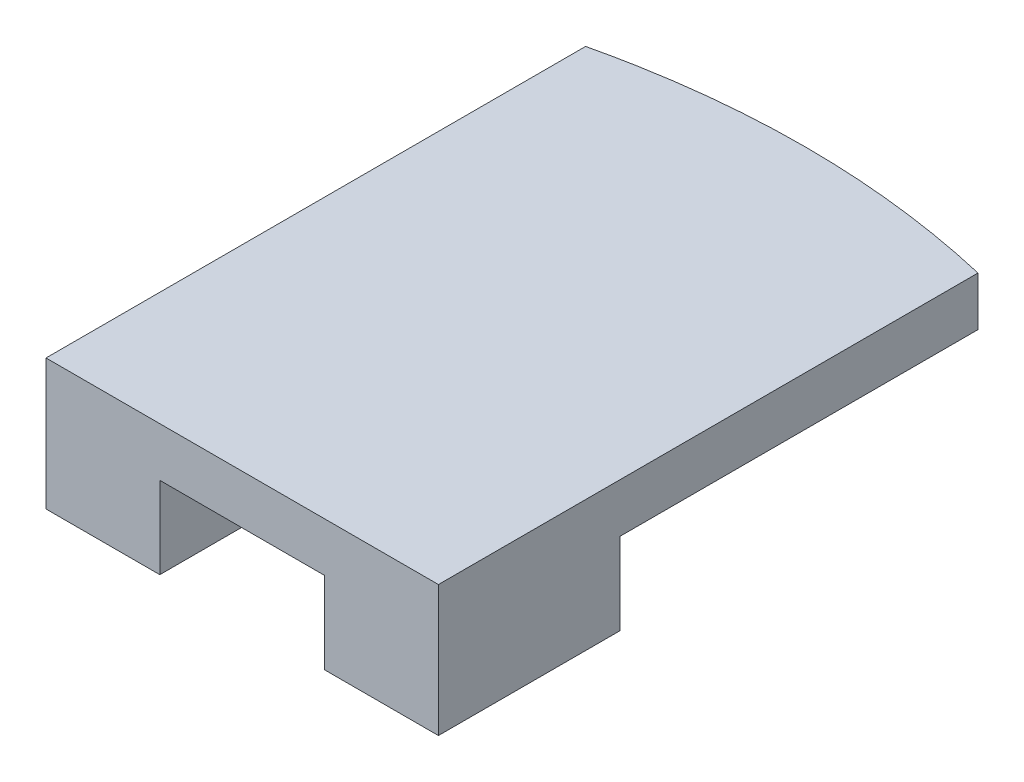
from build123d import *

# Parameters (mm, degrees)
BOSS_EXTRUDE1_DEPTH = 3
SKETCH4_W           = 24
SKETCH4_H           = 0.6
CUT_EXTRUDE3_DEPTH  = 4.0000001
SKETCH5_W           = 6.959988298
SKETCH5_H           = 11.094755151
BOSS_EXTRUDE2_DEPTH = 5


with BuildPart() as part:
    # Sketch1 → Boss-Extrude1 (new body)
    with BuildSketch(Plane(origin=(0, 0, 0), x_dir=(1, 0, 0), z_dir=(0, 1, 0))):
        with BuildLine():
            Line((0, 0), (24, 0))
            Line((24, 0), (24, 33.6))
            add(Edge.make_bspline(
                [(0, 33.6), (12, 36.4), (24, 33.6)],
                knots=[0, 0, 0, 1, 1, 1], degree=2))
            Line((0, 33.6), (0, 0))
        make_face()
    extrude(amount=BOSS_EXTRUDE1_DEPTH)

    # Sketch4 → Cut-Extrude3 (cut, through all)
    with BuildSketch(Plane(origin=(0, 3, 0), x_dir=(1, 0, 0), z_dir=(0, 1, 0))):
        with Locations((12, 0.3)):
            Rectangle(SKETCH4_W, SKETCH4_H)
    extrude(amount=-CUT_EXTRUDE3_DEPTH, mode=Mode.SUBTRACT)

    # Sketch5 → Boss-Extrude2 (add)
    with BuildSketch(Plane.XZ):
        with Locations((3.479994149, -6.147377576)):
            Rectangle(SKETCH5_W, SKETCH5_H)
        with Locations((20.520005851, -6.147377576)):
            Rectangle(SKETCH5_W, SKETCH5_H)
    extrude(amount=BOSS_EXTRUDE2_DEPTH)


solid = part.part
